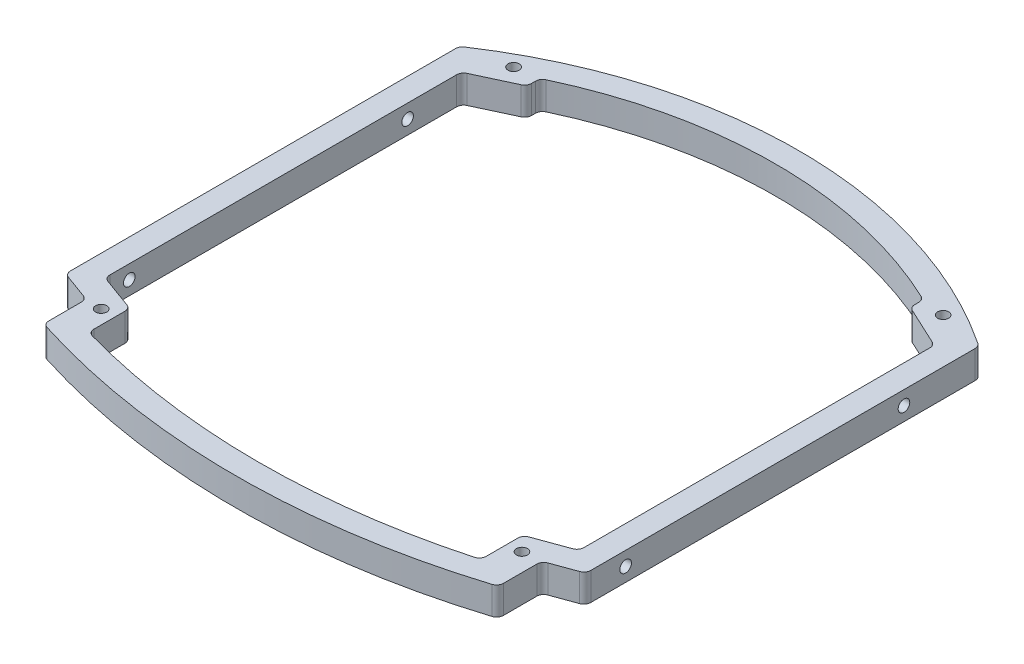
from build123d import *

# Parameters (mm, degrees)
SKETCH1_R                        = 1.2
BOSS_EXTRUDE1_DEPTH              = 6
TAP_DRILL_FOR_M3_TAP1_AT_2_COUNT = 2
TAP_DRILL_FOR_M3_TAP1_AT_2_PITCH = 60
FILLET1_R                        = 1.5


with BuildPart() as part:
    # Sketch1 → Boss-Extrude1 (new body)
    with BuildSketch(Plane(origin=(0, 0, 0), x_dir=(1, 0, 0), z_dir=(0, 1, 0))):
        with BuildLine():
            Line((-56, -46.878887336), (-56, 38))
            ThreePointArc((-56, 38), (0, 55.150739291), (56, 38))
            Line((56, 38), (56, -46.696902219))
            Line((56, -46.696902219), (49, -49.244693859))
            Line((49, -49.244693859), (49, -58.574358685))
            ThreePointArc((49, -58.574358685), (0, -66.262179264), (-49, -58.574358685))
            Line((-49, -58.574358685), (-49, -49.426678976))
            Line((-49, -49.426678976), (-56, -46.878887336))
        make_face()
        with Locations((-46.3, 40)):
            Circle(SKETCH1_R, mode=Mode.SUBTRACT)
        with Locations((46.3, 40)):
            Circle(SKETCH1_R, mode=Mode.SUBTRACT)
        with Locations((45.1, -49.6)):
            Circle(SKETCH1_R, mode=Mode.SUBTRACT)
        with Locations((-45.6, -49.6)):
            Circle(SKETCH1_R, mode=Mode.SUBTRACT)
        with BuildLine():
            Line((-51, -43.377849645), (-51, 33.394842331))
            Line((-51, 33.394842331), (-41.3, 37.918026615))
            Line((-41.3, 37.918026615), (-41.3, 40.703705341))
            ThreePointArc((-41.3, 40.703705341), (0, 50.150739291), (41.3, 40.703705341))
            Line((41.3, 40.703705341), (41.3, 37.918026615))
            Line((41.3, 37.918026615), (51, 33.394842331))
            Line((51, 33.394842331), (51, -43.195864528))
            Line((51, -43.195864528), (42.1, -46.435199613))
            Line((42.1, -46.435199613), (42.1, -55.435199613))
            ThreePointArc((42.1, -55.435199613), (-0.259888817, -61.261961386), (-42.6, -55.29318275))
            Line((-42.6, -55.29318275), (-42.6, -46.435199613))
            Line((-42.6, -46.435199613), (-51, -43.377849645))
        make_face(mode=Mode.SUBTRACT)
    extrude(amount=BOSS_EXTRUDE1_DEPTH)

    # Sketch2 → Tap Drill for M3 Tap1 (revolve, cut)
    with BuildSketch(Plane(origin=(-56, 3, -21.857868774), x_dir=(0, 0, 1), z_dir=(0, 1, 0))):
        Polygon((0, 0), (0, 10.751075774), (1.25, 10), (1.25, 0), align=None)
    tap_drill_for_m3_tap1 = revolve(axis=Axis((-62.35, 3, -21.857868774), (1, 0, 0)), mode=Mode.SUBTRACT)

    # Tap Drill for M3 Tap1 at 2: Tap Drill for M3 Tap1 ×2
    with Locations(*[(0, 0, i * TAP_DRILL_FOR_M3_TAP1_AT_2_PITCH) for i in range(1, TAP_DRILL_FOR_M3_TAP1_AT_2_COUNT)]):
        add(tap_drill_for_m3_tap1, mode=Mode.SUBTRACT)

    # Mirror1: Tap Drill for M3 Tap1 across plane
    add(tap_drill_for_m3_tap1.mirror(Plane(origin=(0, 0, 0), x_dir=(0, 0, 1), z_dir=(1, 0, 0))), mode=Mode.SUBTRACT)

    # Mirror1 copy 1 sketch → Mirror1 copy 1 (revolve, cut)
    with BuildSketch(Plane(origin=(56, 3, 38.142131226), x_dir=(0, 0, 1), z_dir=(0, 1, 0))):
        Polygon((0, 0), (0, -10.751075774), (1.25, -10), (1.25, 0), align=None)
    revolve(axis=Axis((62.35, 3, 38.142131226), (1, 0, 0)), mode=Mode.SUBTRACT)

    # Fillet1
    fillet1_edges = [part.edges().sort_by_distance(p)[0] for p in [
        (49, 3, 49.244693859),
        (49, 3, 58.574358685),
        (-49, 3, 58.574358685),
        (-49, 3, 49.426678976),
        (-56, 3, 46.878887336),
        (-56, 3, -38),
        (56, 3, -38),
        (56, 3, 46.696902219),
        (-51, 3, 43.377849645),
        (-42.6, 3, 46.435199613),
        (-42.6, 3, 55.29318275),
        (42.1, 3, 55.435199613),
        (42.1, 3, 46.435199613),
        (51, 3, 43.195864528),
        (51, 3, -33.394842331),
        (41.3, 3, -37.918026615),
        (41.3, 3, -40.703705341),
        (-41.3, 3, -40.703705341),
        (-41.3, 3, -37.918026615),
        (-51, 3, -33.394842331),
    ]]
    fillet(fillet1_edges, radius=FILLET1_R)


solid = part.part
